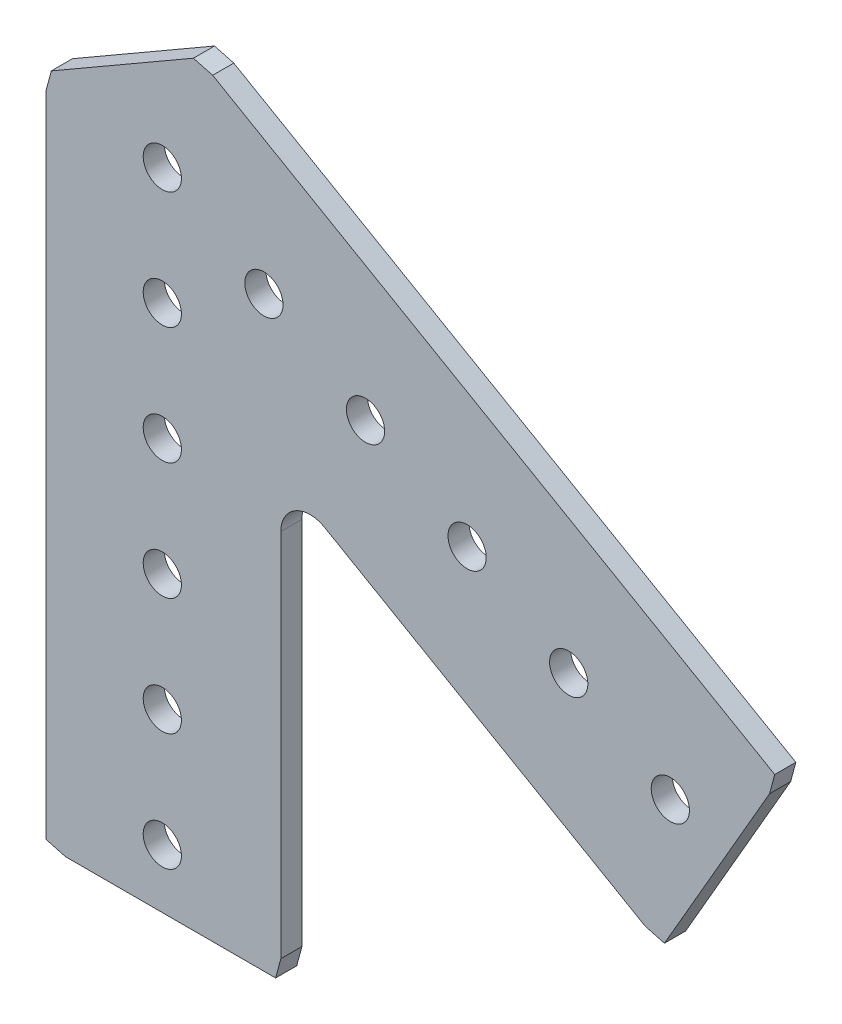
from build123d import *

# Parameters (mm, degrees)
SKETCH1_R           = 2.0701
BOSS_EXTRUDE1_DEPTH = 2.286


with BuildPart() as part:
    # Sketch1 → Boss-Extrude1 (new body)
    with BuildSketch(Plane.XY.offset(2.286)):
        with BuildLine():
            Line((17.5895, -24.966646366), (52.272335755, -44.990790925))
            Line((52.272335755, -44.990790925), (54.357769614, -45.549581243))
            Line((54.357769614, -45.549581243), (65.735657525, -25.842501298))
            Line((65.735657525, -25.842501298), (66.294447843, -23.757067439))
            Line((66.294447843, -23.757067439), (5.451427483, 11.370666744))
            Line((5.451427483, 11.370666744), (3.365993624, 11.929457063))
            Line((3.365993624, 11.929457063), (-12.014209682, 3.049692544))
            Line((-12.014209682, 3.049692544), (-12.573, 0.964258685))
            Line((-12.573, 0.964258685), (-12.573, -69.291209682))
            Line((-12.573, -69.291209682), (-10.487566141, -69.85))
            Line((-10.487566141, -69.85), (12.268209682, -69.85))
            Line((12.268209682, -69.85), (12.827, -67.764566141))
            Line((12.827, -67.764566141), (12.827, -27.716277023))
            ThreePointArc((12.827, -27.716277023), (14.4145, -24.966646366), (17.5895, -24.966646366))
        make_face()
        with Locations((54.99261314, -31.75)):
            Circle(SKETCH1_R, mode=Mode.SUBTRACT)
        with Locations((32.995567884, -19.05)):
            Circle(SKETCH1_R, mode=Mode.SUBTRACT)
        with Locations((0, -50.8)):
            Circle(SKETCH1_R, mode=Mode.SUBTRACT)
        with Locations((0, -25.4)):
            Circle(SKETCH1_R, mode=Mode.SUBTRACT)
        with Locations((10.998522628, -6.35)):
            Circle(SKETCH1_R, mode=Mode.SUBTRACT)
        Circle(SKETCH1_R, mode=Mode.SUBTRACT)
        with Locations((0, -12.7)):
            Circle(SKETCH1_R, mode=Mode.SUBTRACT)
        with Locations((0, -38.1)):
            Circle(SKETCH1_R, mode=Mode.SUBTRACT)
        with Locations((21.997045256, -12.7)):
            Circle(SKETCH1_R, mode=Mode.SUBTRACT)
        with Locations((43.994090512, -25.4)):
            Circle(SKETCH1_R, mode=Mode.SUBTRACT)
        with Locations((0, -63.5)):
            Circle(SKETCH1_R, mode=Mode.SUBTRACT)
    extrude(amount=-BOSS_EXTRUDE1_DEPTH)


solid = part.part
